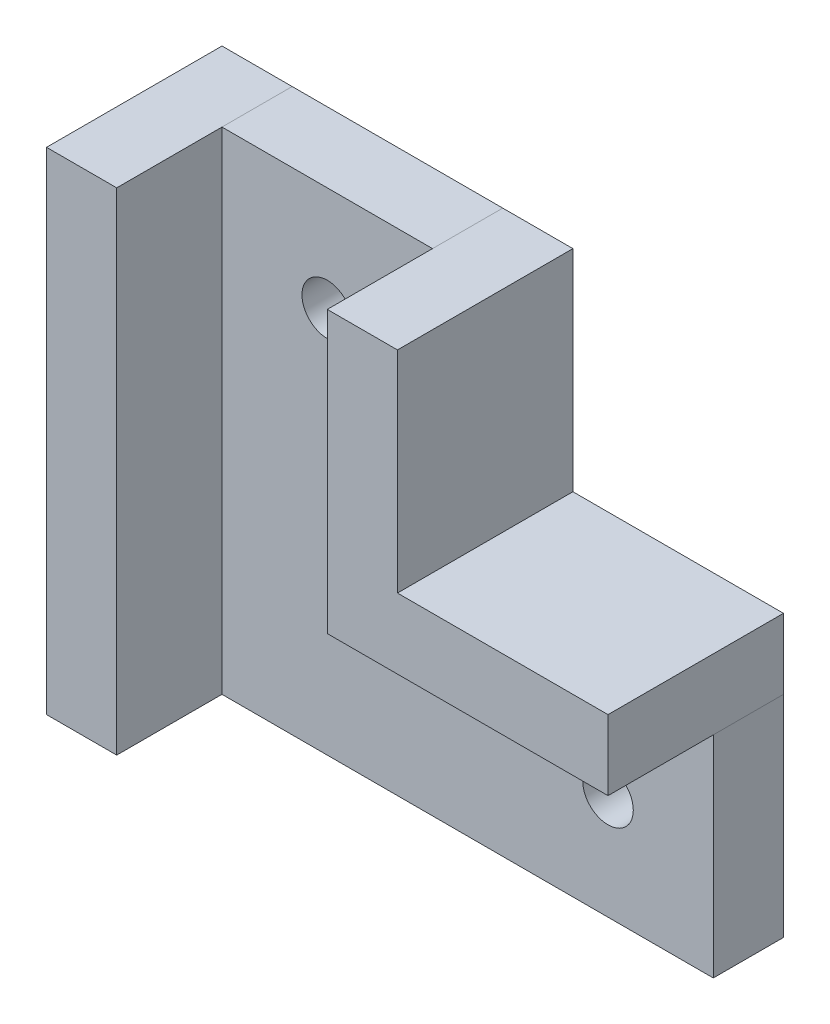
from build123d import *

# Parameters (mm, degrees)
BOSS_EXTRUDE1_DEPTH = 5
BOSS_EXTRUDE2_DEPTH = 12.5
SKETCH3_W           = 5
SKETCH3_H           = 35
BOSS_EXTRUDE3_DEPTH = 12.5
SKETCH4_R           = 1.8
CUT_EXTRUDE1_DEPTH  = 13.5


with BuildPart() as part:
    # Sketch1 → Boss-Extrude1 (new body)
    with BuildSketch(Plane.XY):
        Polygon((-7.529880478, -25.806772908), (27.470119522, -25.806772908), (27.470119522, -10.806772908), (7.470119522, -10.806772908), (7.470119522, 9.193227092), (-7.529880478, 9.193227092), align=None)
    extrude(amount=BOSS_EXTRUDE1_DEPTH)

    # Sketch4 → Cut-Extrude1 (cut, through all)
    with BuildSketch(Plane(origin=(0, 0, 0), x_dir=(-1, 0, 0), z_dir=(0, 0, -1))):
        with Locations((0.029880478, 1.693227092)):
            Circle(SKETCH4_R)
        with Locations((-19.970119522, -18.306772908)):
            Circle(SKETCH4_R)
    extrude(amount=-CUT_EXTRUDE1_DEPTH, mode=Mode.SUBTRACT)


with BuildPart() as body_2:
    # Sketch2 → Boss-Extrude2 (new body)
    with BuildSketch(Plane(origin=(0, 0, 0), x_dir=(-1, 0, 0), z_dir=(0, 0, -1))):
        Polygon((-7.470119522, 9.193227092), (-12.470119522, 9.193227092), (-12.470119522, -5.806772908), (-27.470119522, -5.806772908), (-27.470119522, -10.806772908), (-7.470119522, -10.806772908), align=None)
    extrude(amount=-BOSS_EXTRUDE2_DEPTH)


with BuildPart() as body_3:
    # Sketch3 → Boss-Extrude3 (new body)
    with BuildSketch(Plane(origin=(0, 0, 0), x_dir=(-1, 0, 0), z_dir=(0, 0, -1))):
        with Locations((10.029880478, -8.306772908)):
            Rectangle(SKETCH3_W, SKETCH3_H)
    extrude(amount=-BOSS_EXTRUDE3_DEPTH)


solid = Compound([part.part, body_2.part, body_3.part])
